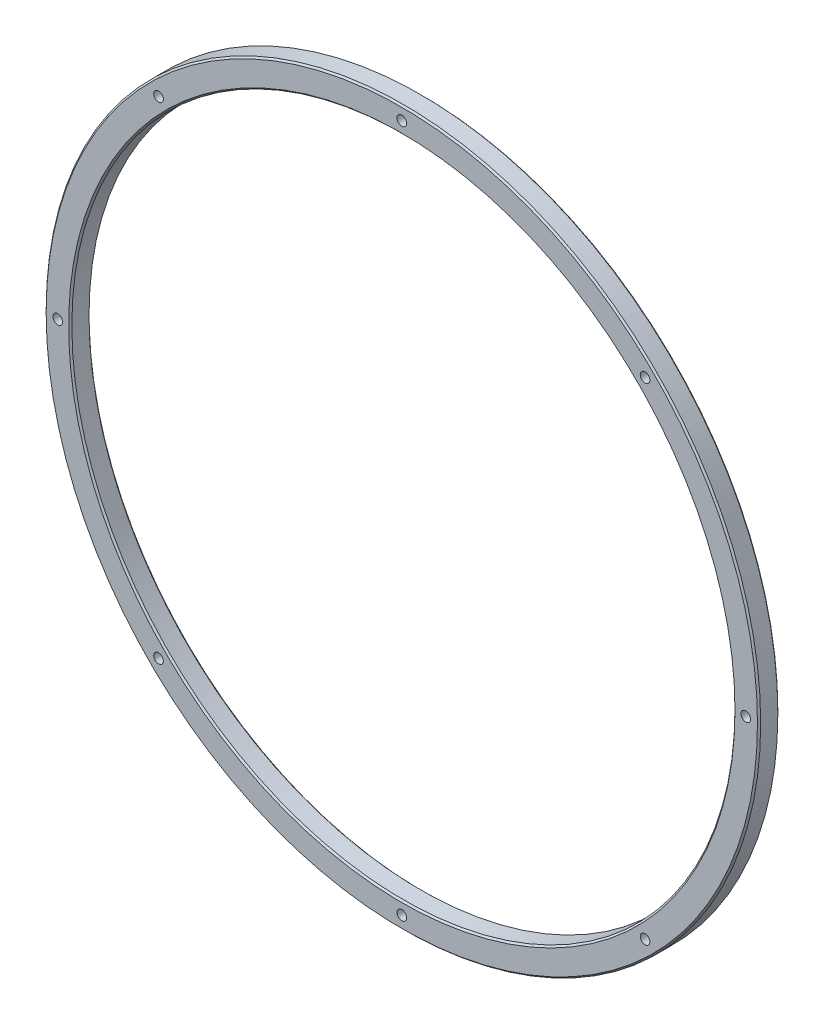
from build123d import *

# Parameters (mm, degrees)
SKETCH1_R             = 111.25
SKETCH1_R_2           = 103.25
EXTRUDE1_DEPTH        = 6.35
M3X0_5_TAPPED_HOLE1_D = 3
CIRPATTERN1_COUNT     = 8
CHAMFER1_SIZE         = 0.5


with BuildPart() as part:
    # Sketch1 → Extrude1 (new body)
    with BuildSketch(Plane.XY):
        Circle(SKETCH1_R)
        Circle(SKETCH1_R_2, mode=Mode.SUBTRACT)
    extrude(amount=EXTRUDE1_DEPTH)

    # M3x0.5 Tapped Hole1 (through all)
    with Locations(Plane.XY.offset(6.35)):
        with Locations((0, 107.125)):
            m3x0_5_tapped_hole1 = Hole(M3X0_5_TAPPED_HOLE1_D / 2)

    # CirPattern1: M3x0.5 Tapped Hole1 ×8 about axis
    cirpattern1_axis = Axis((0, 0, 0), (0, 0, 1))
    for i in range(1, CIRPATTERN1_COUNT):
        add(m3x0_5_tapped_hole1.rotate(cirpattern1_axis, i * 360 / CIRPATTERN1_COUNT), mode=Mode.SUBTRACT)

    # Chamfer1
    chamfer1_edges = [part.edges().sort_by_distance(p)[0] for p in [
        (-111.25, 0, 0),
        (-111.25, 0, 6.35),
        (-103.25, 0, 0),
        (-103.25, 0, 6.35),
    ]]
    chamfer(chamfer1_edges, length=CHAMFER1_SIZE)


solid = part.part
